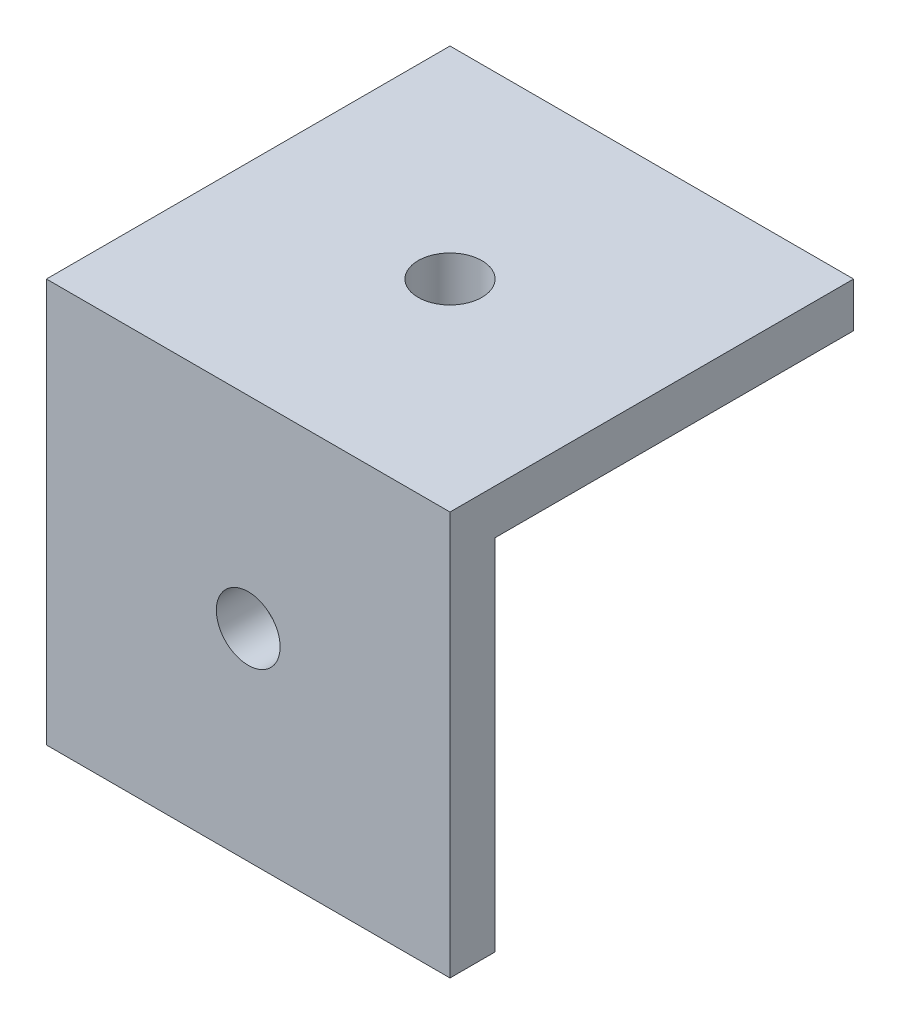
from build123d import *

# Parameters (mm, degrees)
SKETCH2_W           = 18
SKETCH2_H           = 18
BOSS_EXTRUDE1_DEPTH = 18
SKETCH3_R           = 1.4224
CUT_EXTRUDE1_DEPTH  = 6.6
SKETCH4_R           = 1.4224
CUT_EXTRUDE2_DEPTH  = 6.6
SKETCH5_R           = 1.4224
CUT_EXTRUDE3_DEPTH  = 6.6
SKETCH6_W           = 16
SKETCH6_H           = 16
CUT_EXTRUDE4_DEPTH  = 16
SKETCH7_W           = 16
SKETCH7_H           = 16
CUT_EXTRUDE5_DEPTH  = 10


with BuildPart() as part:
    # Sketch2 → Boss-Extrude1 (new body)
    with BuildSketch(Plane(origin=(0, 0, 0), x_dir=(1, 0, 0), z_dir=(0, 1, 0))):
        Rectangle(SKETCH2_W, SKETCH2_H)
    extrude(amount=BOSS_EXTRUDE1_DEPTH)

    # Sketch3 → Cut-Extrude1 (cut)
    with BuildSketch(Plane(origin=(0, 18, 0), x_dir=(1, 0, 0), z_dir=(0, 1, 0))):
        Circle(SKETCH3_R)
    extrude(amount=-CUT_EXTRUDE1_DEPTH, mode=Mode.SUBTRACT)

    # Sketch4 → Cut-Extrude2 (cut)
    with BuildSketch(Plane(origin=(9, 0, 0), x_dir=(0, 0, -1), z_dir=(1, 0, 0))):
        with Locations((0, 9)):
            Circle(SKETCH4_R)
    extrude(amount=-CUT_EXTRUDE2_DEPTH, mode=Mode.SUBTRACT)

    # Sketch5 → Cut-Extrude3 (cut)
    with BuildSketch(Plane.XY.offset(9)):
        with Locations((0, 9)):
            Circle(SKETCH5_R)
    extrude(amount=-CUT_EXTRUDE3_DEPTH, mode=Mode.SUBTRACT)

    # Sketch6 → Cut-Extrude4 (cut)
    with BuildSketch(Plane(origin=(0, 0, -9), x_dir=(-1, 0, 0), z_dir=(0, 0, -1))):
        with Locations((1, 8)):
            Rectangle(SKETCH6_W, SKETCH6_H)
    extrude(amount=-CUT_EXTRUDE4_DEPTH, mode=Mode.SUBTRACT)

    # Sketch7 → Cut-Extrude5 (cut)
    with BuildSketch(Plane.ZY.offset(-7)):
        with Locations((-1, 8)):
            Rectangle(SKETCH7_W, SKETCH7_H)
    extrude(amount=-CUT_EXTRUDE5_DEPTH, mode=Mode.SUBTRACT)


solid = part.part
